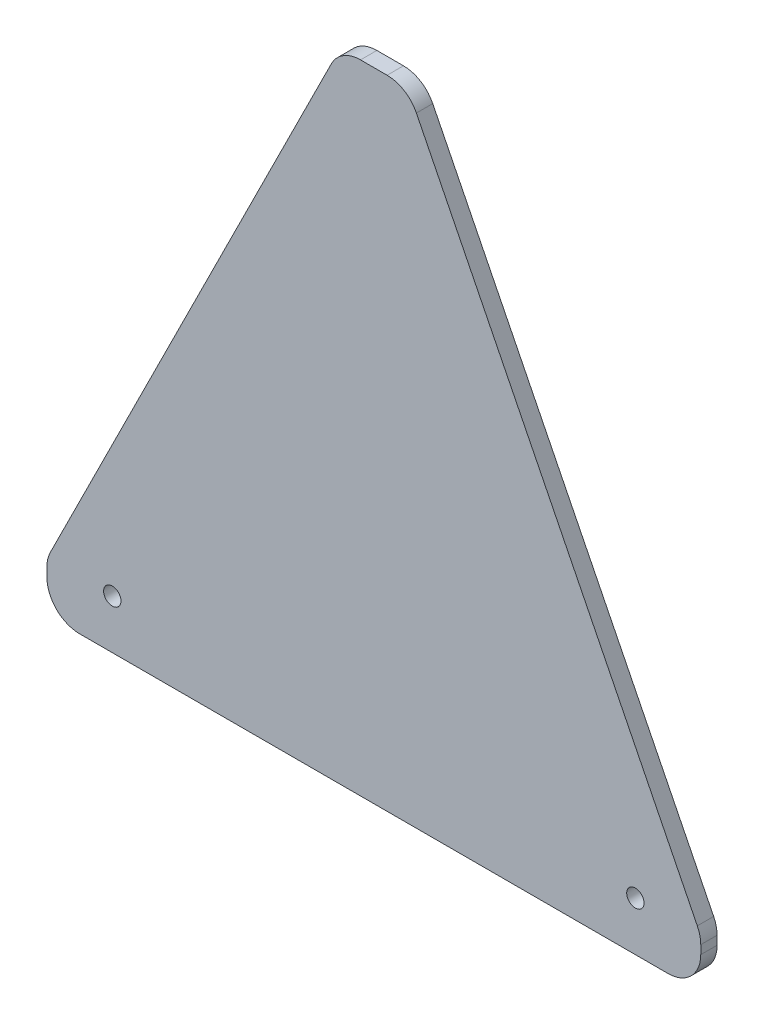
from build123d import *

# Parameters (mm, degrees)
SKETCH1_R           = 3.3734375
BOSS_EXTRUDE1_DEPTH = 6.35
FILLET2_R           = 12.7


with BuildPart() as part:
    # Sketch1 → Boss-Extrude1 (new body)
    with BuildSketch(Plane.XY):
        Polygon((0, 0), (254, 0), (254, 19.05), (140.024244399, 247.65), (113.975755601, 247.65), (0, 19.05), align=None)
        with Locations((25.4, 19.05)):
            Circle(SKETCH1_R, mode=Mode.SUBTRACT)
        with Locations((228.6, 19.05)):
            Circle(SKETCH1_R, mode=Mode.SUBTRACT)
    extrude(amount=BOSS_EXTRUDE1_DEPTH)

    # Fillet2
    fillet2_edges = [part.edges().sort_by_distance(p)[0] for p in [
        (0, 19.05, 3.175),
        (113.975755601, 247.65, 3.175),
        (140.024244399, 247.65, 3.175),
        (254, 19.05, 3.175),
        (254, 0, 3.175),
        (0, 0, 3.175),
    ]]
    fillet(fillet2_edges, radius=FILLET2_R)


solid = part.part
